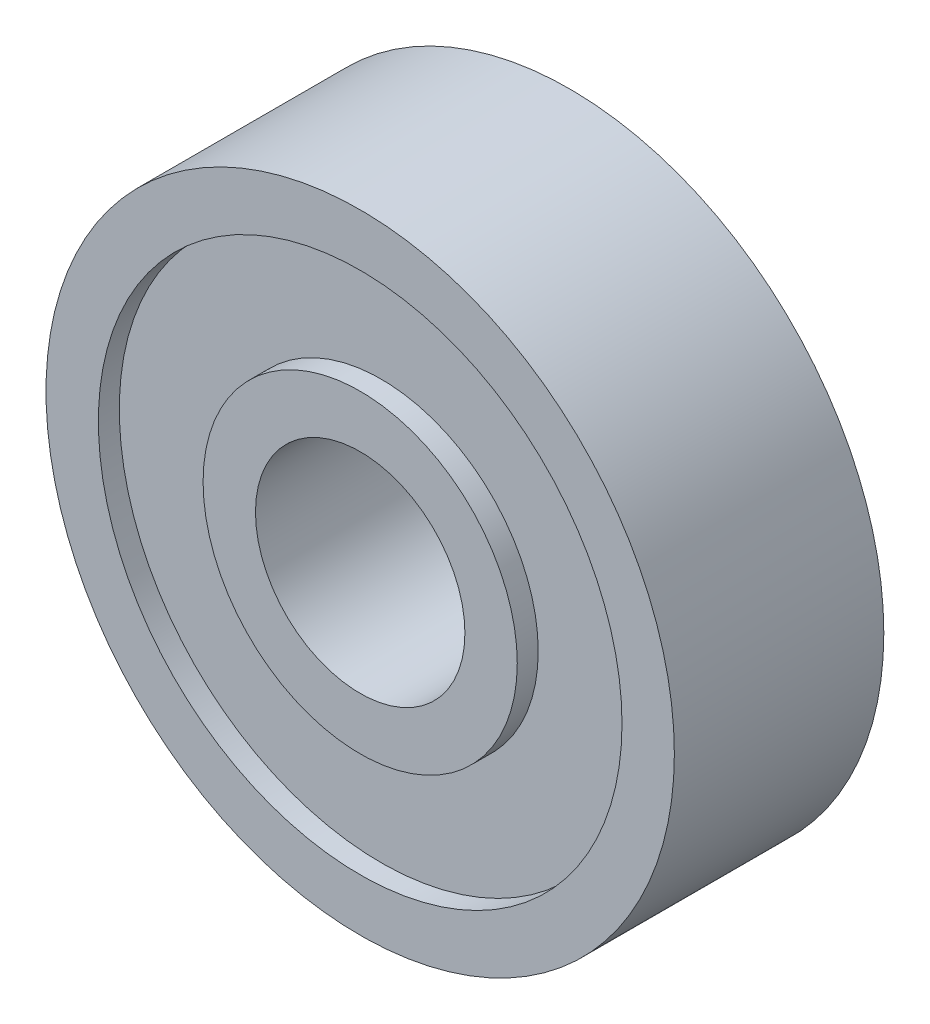
from build123d import *

# Parameters (mm, degrees)
SKETCH2_R             = 7.5
SKETCH2_R_2           = 5
BOSS_EXTRUDE1_DEPTH   = 10
SKETCH2_R_3           = 15
SKETCH2_R_4           = 12.5
BOSS_EXTRUDE1_2_DEPTH = 10
SKETCH2_3_R           = 12.5
SKETCH2_3_R_2         = 7.5
BOSS_EXTRUDE2_DEPTH   = 9


with BuildPart() as part:
    # Sketch2 → Boss-Extrude1 (new body)
    with BuildSketch(Plane.XY):
        Circle(SKETCH2_R)
        Circle(SKETCH2_R_2, mode=Mode.SUBTRACT)
    extrude(amount=BOSS_EXTRUDE1_DEPTH)



with BuildPart() as body_2:
    # Sketch2 → Boss-Extrude1 2 (new body)
    with BuildSketch(Plane.XY):
        Circle(SKETCH2_R_3)
        Circle(SKETCH2_R_4, mode=Mode.SUBTRACT)
    extrude(amount=BOSS_EXTRUDE1_2_DEPTH)


with BuildPart() as part_1:
    add(part.part)

    add(body_2.part)  # Boss-Extrude2 merges body 2
    # Sketch2_3 → Boss-Extrude2 (add)
    with BuildSketch(Plane.XY):
        Circle(SKETCH2_3_R)
        Circle(SKETCH2_3_R_2, mode=Mode.SUBTRACT)
    extrude(amount=BOSS_EXTRUDE2_DEPTH)


solid = part_1.part
